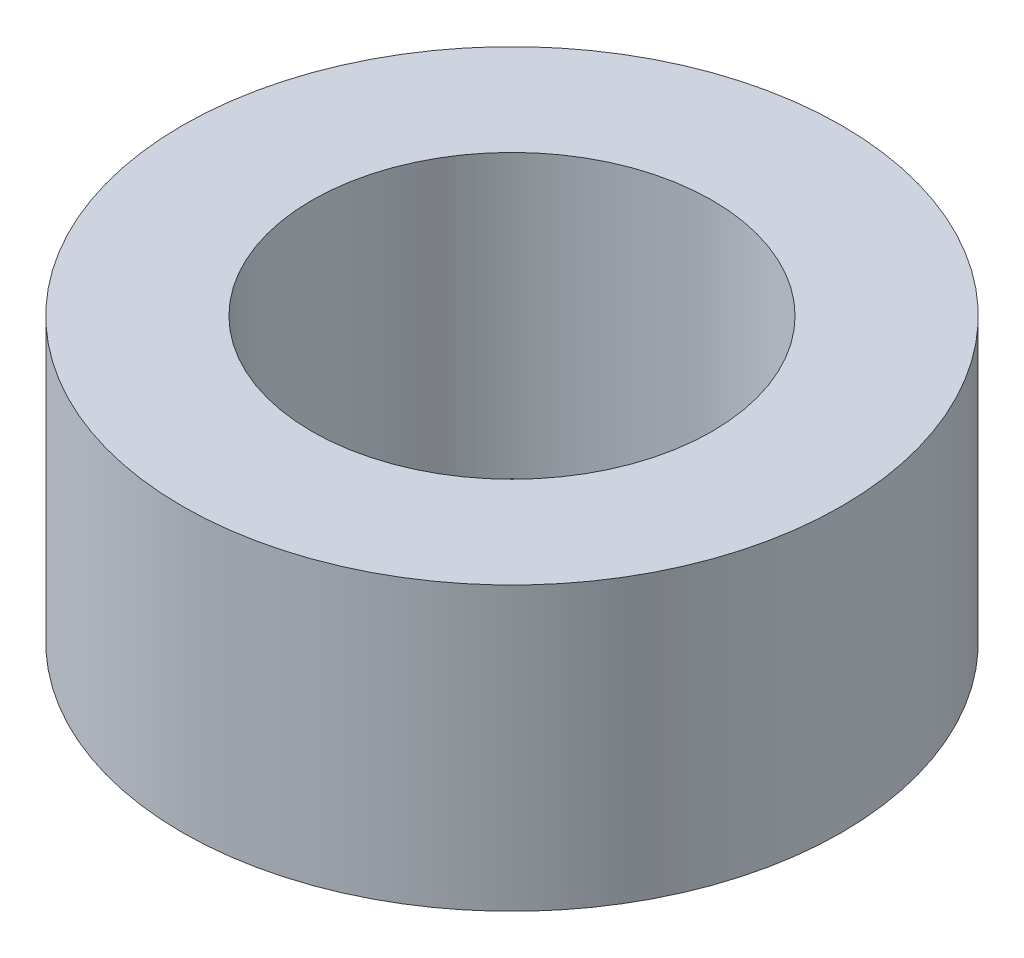
from build123d import *

# Parameters (mm, degrees)
SKETCH1_R           = 3.5
SKETCH1_R_2         = 2.125
BOSS_EXTRUDE1_DEPTH = 3


with BuildPart() as part:
    # Sketch1 → Boss-Extrude1 (new body)
    with BuildSketch(Plane(origin=(0, 0, 0), x_dir=(1, 0, 0), z_dir=(0, 1, 0))):
        Circle(SKETCH1_R)
        Circle(SKETCH1_R_2, mode=Mode.SUBTRACT)
    extrude(amount=BOSS_EXTRUDE1_DEPTH)


solid = part.part
